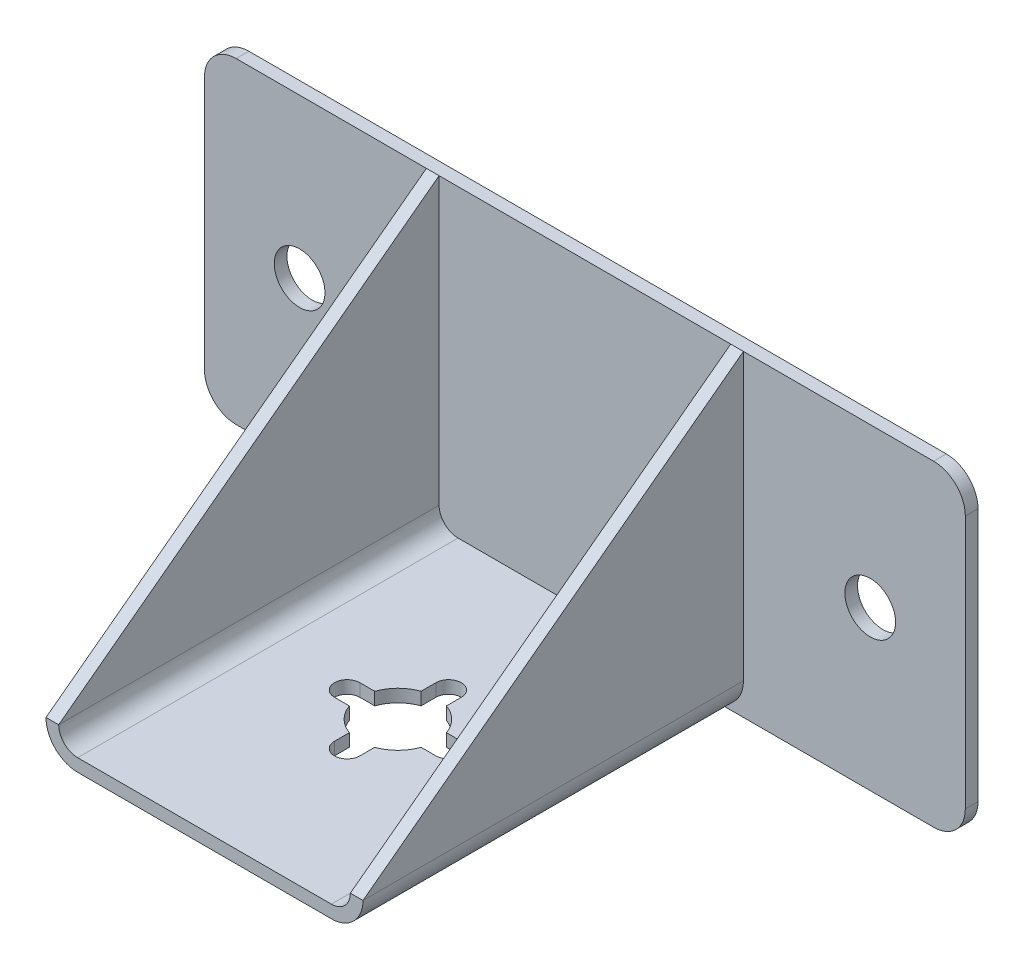
from build123d import *

# Parameters (mm, degrees)
SALIENTE_EXTRUIR1_DEPTH = 2
SALIENTE_EXTRUIR2_DEPTH = 60
CORTAR_EXTRUIR1_DEPTH   = 50
CROQUIS4_R              = 4
CORTAR_EXTRUIR2_DEPTH   = 2
CORTAR_EXTRUIR6_DEPTH   = 2


with BuildPart() as part:
    # Croquis1 → Saliente-Extruir1 (new body)
    with BuildSketch(Plane.XY):
        with BuildLine():
            Line((-55, -25), (55, -25))
            ThreePointArc((55, -25), (58.535533906, -23.535533906), (60, -20))
            Line((60, -20), (60, 20))
            ThreePointArc((60, 20), (58.535533906, 23.535533906), (55, 25))
            Line((55, 25), (-55, 25))
            ThreePointArc((-55, 25), (-58.535533906, 23.535533906), (-60, 20))
            Line((-60, 20), (-60, -20))
            ThreePointArc((-60, -20), (-58.535533906, -23.535533906), (-55, -25))
        make_face()
    extrude(amount=SALIENTE_EXTRUIR1_DEPTH)

    # Croquis2 → Saliente-Extruir2 (add)
    with BuildSketch(Plane.XY.offset(2)):
        with BuildLine():
            Line((-20, -25), (20, -25))
            ThreePointArc((20, -25), (23.535533906, -23.535533906), (25, -20))
            Line((25, -20), (25, 25))
            Line((25, 25), (23, 25))
            Line((23, 25), (23, -20))
            ThreePointArc((23, -20), (22.121320344, -22.121320344), (20, -23))
            Line((20, -23), (-20, -23))
            ThreePointArc((-20, -23), (-22.121320344, -22.121320344), (-23, -20))
            Line((-23, -20), (-23, 25))
            Line((-23, 25), (-25, 25))
            Line((-25, 25), (-25, -20))
            ThreePointArc((-25, -20), (-23.535533906, -23.535533906), (-20, -25))
        make_face()
    extrude(amount=SALIENTE_EXTRUIR2_DEPTH)

    # Croquis3 → Cortar-Extruir1 (cut)
    with BuildSketch(Plane(origin=(25, 0, 0), x_dir=(0, 0, -1), z_dir=(1, 0, 0))):
        Polygon((-62, -20), (-2, 25), (-62, 25), align=None)
    extrude(amount=-CORTAR_EXTRUIR1_DEPTH, mode=Mode.SUBTRACT)

    # Croquis4 → Cortar-Extruir2 (cut)
    with BuildSketch(Plane(origin=(0, 0, 0), x_dir=(-1, 0, 0), z_dir=(0, 0, -1))):
        with Locations((-45, 0)):
            Circle(CROQUIS4_R)
        with Locations((45, 0)):
            Circle(CROQUIS4_R)
    extrude(amount=-CORTAR_EXTRUIR2_DEPTH, mode=Mode.SUBTRACT)

    # Croquis5 → Cortar-Extruir6 (cut)
    with BuildSketch(Plane.XZ.offset(25)):
        with BuildLine():
            ThreePointArc((-2, 23.499997), (0, 21.499997), (2, 23.499997))
            Line((2, 23.499997), (2, 25.84314275))
            ThreePointArc((2, 25.84314275), (4.242640687, 27.257356313), (5.656854249, 29.499997))
            Line((5.656854249, 29.499997), (8, 29.499997))
            ThreePointArc((8, 29.499997), (10, 31.499997), (8, 33.499997))
            Line((8, 33.499997), (5.656854249, 33.499997))
            ThreePointArc((5.656854249, 33.499997), (4.242640687, 35.742637687), (2, 37.156851249))
            Line((2, 37.156851249), (2, 39.499997))
            ThreePointArc((2, 39.499997), (0, 41.499997), (-2, 39.499997))
            Line((-2, 39.499997), (-2, 37.156851249))
            ThreePointArc((-2, 37.156851249), (-4.242640687, 35.742637687), (-5.656854249, 33.499997))
            Line((-5.656854249, 33.499997), (-8, 33.499997))
            ThreePointArc((-8, 33.499997), (-10, 31.499997), (-8, 29.499997))
            Line((-8, 29.499997), (-5.656854249, 29.499997))
            ThreePointArc((-5.656854249, 29.499997), (-4.242640687, 27.257356313), (-2, 25.84314275))
            Line((-2, 25.84314275), (-2, 23.499997))
        make_face()
    extrude(amount=-CORTAR_EXTRUIR6_DEPTH, mode=Mode.SUBTRACT)


solid = part.part
